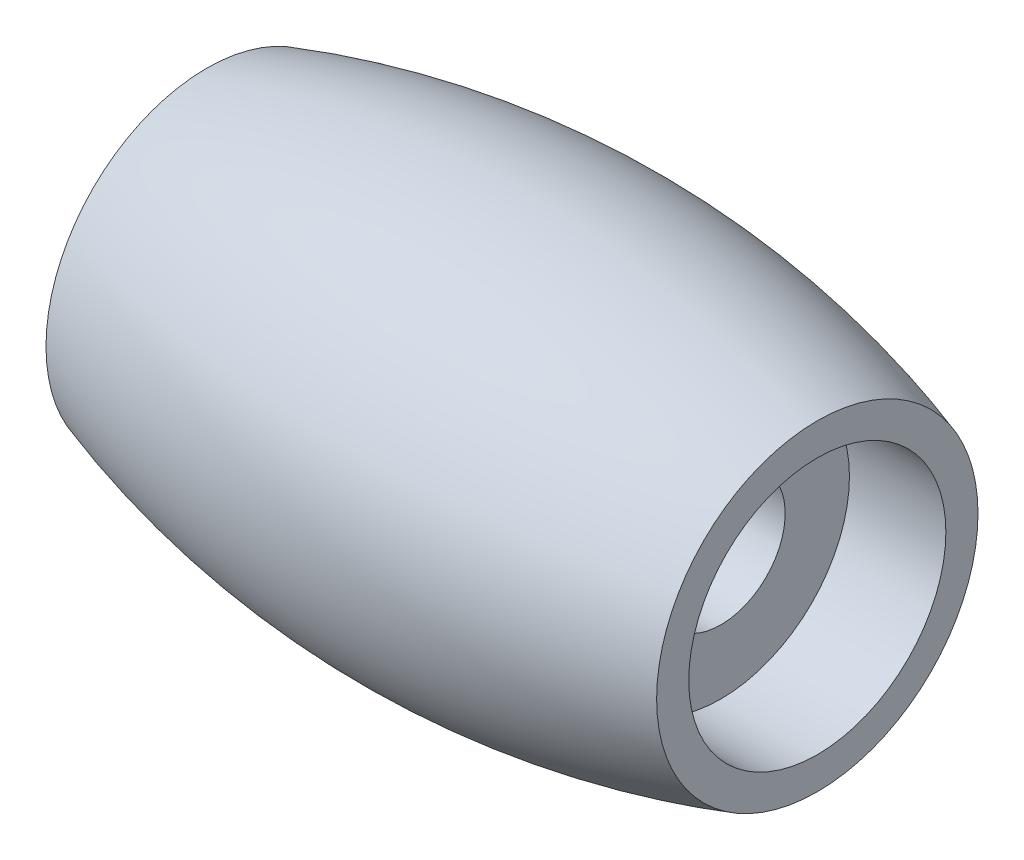
from build123d import *


with BuildPart() as part:
    # Sketch1 → Revolve1 (revolve)
    with BuildSketch(Plane.XY):
        with BuildLine():
            Line((0, 4), (0, 5))
            ThreePointArc((0, 5), (9.5, 6.500017046), (19, 5))
            Line((19, 5), (19, 4))
            Line((19, 4), (16, 4))
            Line((16, 4), (16, 2))
            Line((16, 2), (3, 2))
            Line((3, 2), (3, 4))
            Line((3, 4), (0, 4))
        make_face()
    revolve(axis=Axis((0, 0, 0), (1, 0, 0)))


solid = part.part
